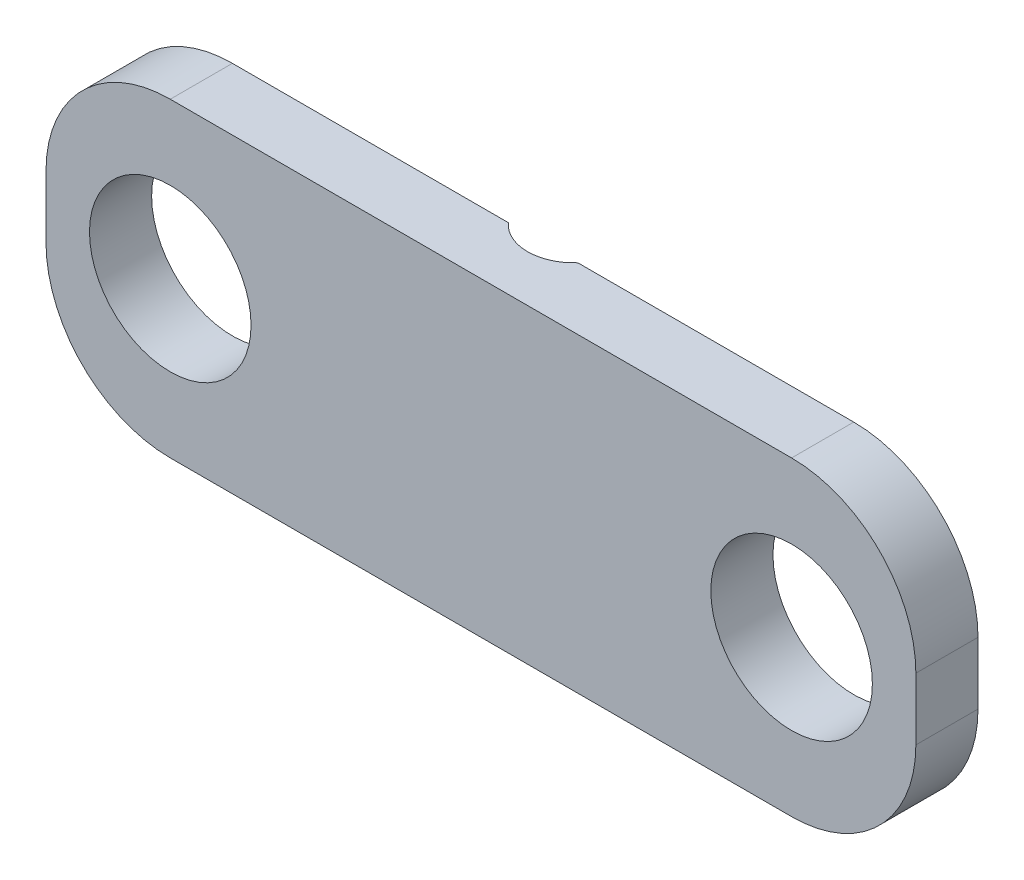
from build123d import *

# Parameters (mm, degrees)
BOSS_EXTRUDE1_DEPTH      = 1
M2_CLEARANCE_HOLE1_D     = 2.6
M2_CLEARANCE_HOLE1_DEPTH = 1
CUT_EXTRUDE1_REACH       = 7
SKETCH15_R               = 0.75


with BuildPart() as part:
    # Sketch2 → Boss-Extrude1 (new body)
    with BuildSketch(Plane.XY):
        with BuildLine():
            Line((-5, 2.5), (5, 2.5))
            ThreePointArc((5, 2.5), (6.414213562, 1.914213562), (7, 0.5))
            Line((7, 0.5), (7, -0.5))
            ThreePointArc((7, -0.5), (6.414213562, -1.914213562), (5, -2.5))
            Line((5, -2.5), (-5, -2.5))
            ThreePointArc((-5, -2.5), (-6.414213562, -1.914213562), (-7, -0.5))
            Line((-7, -0.5), (-7, 0.5))
            ThreePointArc((-7, 0.5), (-6.414213562, 1.914213562), (-5, 2.5))
        make_face()
    extrude(amount=BOSS_EXTRUDE1_DEPTH)

    # M2 Clearance Hole1
    with Locations(Plane(origin=(0, 0, 0), x_dir=(-1, 0, 0), z_dir=(0, 0, -1))):
        with Locations((-5, 0), (5, 0)):
            Hole(M2_CLEARANCE_HOLE1_D / 2, depth=M2_CLEARANCE_HOLE1_DEPTH)

    # Sketch15 → Cut-Extrude1 (cut, up to next)
    with BuildSketch(Plane.XZ.offset(2.5), mode=Mode.PRIVATE) as cut_extrude1_sk1:
        with Locations((0, -0.5)):
            Circle(SKETCH15_R)
    cut_extrude1_tool1 = extrude(cut_extrude1_sk1.sketch, amount=-CUT_EXTRUDE1_REACH, mode=Mode.PRIVATE) & part.part
    add(cut_extrude1_tool1.solids().sort_by_distance((0, -2.5, -0.5))[0], mode=Mode.SUBTRACT)


solid = part.part
